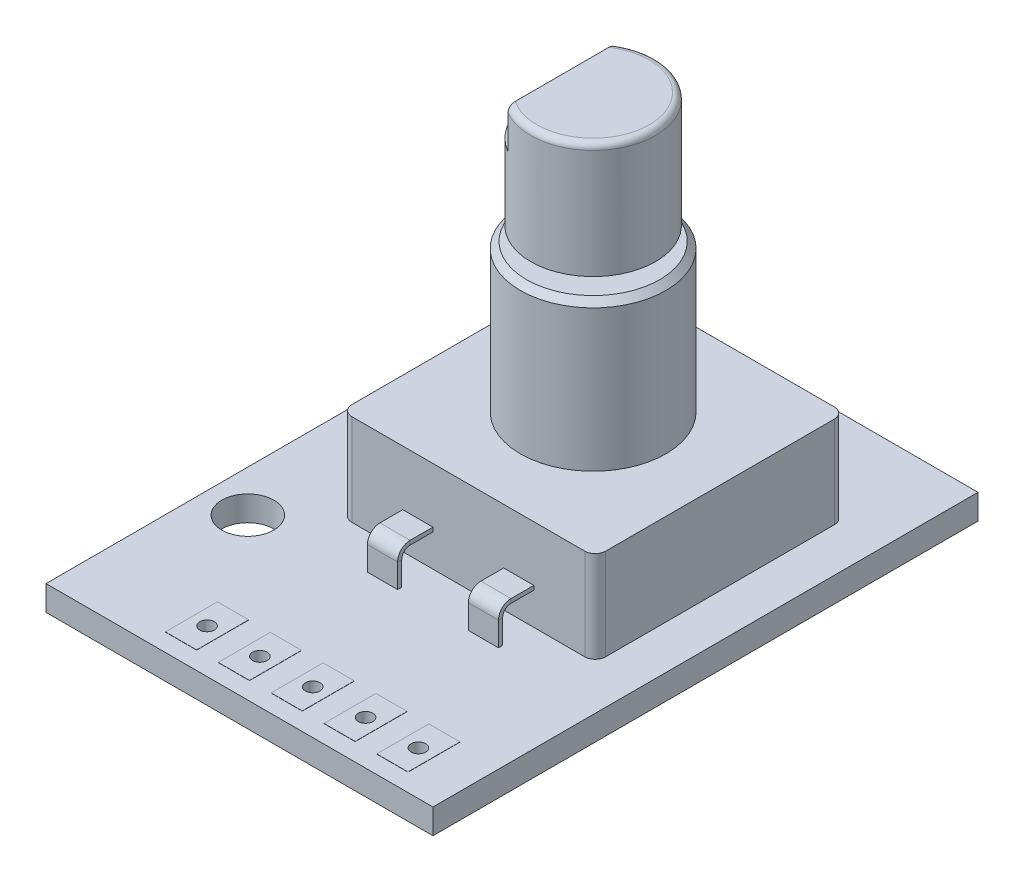
from build123d import *

# Parameters (mm, degrees)
SKETCH1_W             = 18.6
SKETCH1_H             = 26.2
SKETCH1_R             = 1.25
BOSS_EXTRUDE1_DEPTH   = 1.2
SKETCH3_W             = 12.2
SKETCH3_H             = 12
BOSS_EXTRUDE2_DEPTH   = 4.4
SKETCH10_W            = 1.45
SKETCH10_H            = 0.2
SKETCH13_W            = 1.45
SKETCH13_H            = 0.2
LPATTERN1_COUNT       = 2
LPATTERN1_PITCH       = 2.85
LPATTERN2_COUNT       = 2
LPATTERN2_PITCH       = 2.85
SKETCH14_R            = 3.5
BOSS_EXTRUDE4_DEPTH   = 7.1
CHAMFER1_SIZE         = 0.3
SKETCH15_R            = 1.9
BOSS_EXTRUDE5_DEPTH   = 0.65
SKETCH16_R            = 3
BOSS_EXTRUDE6_DEPTH   = 14.45
CHAMFER2_SIZE         = 0.6
CUT_EXTRUDE1_DEPTH    = 10.8
SKETCH18_R            = 0.35
CUT_EXTRUDE2_DEPTH    = 1.2
SKETCH19_W            = 1.5
SKETCH19_H            = 2.5
SKETCH19_R            = 0.35
BOSS_EXTRUDE7_DEPTH   = 0.01
FILLET1_R             = 0.5
CROQUIS1_R            = 3.5
CORTAR_EXTRUIR1_DEPTH = 8.9
REDONDEO1_R           = 0.3


with BuildPart() as part:
    # Sketch1 → Boss-Extrude1 (new body)
    with BuildSketch(Plane(origin=(0, 0, 0), x_dir=(1, 0, 0), z_dir=(0, 1, 0))):
        Rectangle(SKETCH1_W, SKETCH1_H)
        with Locations((-7.3, 8.3)):
            Circle(SKETCH1_R, mode=Mode.SUBTRACT)
        with Locations((-7.3, -5.4)):
            Circle(SKETCH1_R, mode=Mode.SUBTRACT)
    extrude(amount=BOSS_EXTRUDE1_DEPTH)

    # Sketch3 → Boss-Extrude2 (add)
    with BuildSketch(Plane(origin=(0, 1.2, 0), x_dir=(1, 0, 0), z_dir=(0, 1, 0))):
        with Locations((1.1, 2.8)):
            Rectangle(SKETCH3_W, SKETCH3_H)
    extrude(amount=BOSS_EXTRUDE2_DEPTH)

    # Sweep3: sweep along a curve in space
    with BuildLine() as sweep3_path:
        Line((-1.325, 2.85, 3.2), (-1.325, 2.85, 4.3))
        ThreePointArc((-1.325, 2.85, 4.3), (-1.325, 2.703553391, 4.653553391), (-1.325, 2.35, 4.8))
        Line((-1.325, 2.35, 4.8), (-1.325, 1.2, 4.8))
    # Sketch10 → Sweep3 (sweep)
    with BuildSketch(Plane.XY.offset(3.2)):
        with Locations((-1.325, 2.85)):
            Rectangle(SKETCH10_W, SKETCH10_H)
    sweep3 = sweep(path=sweep3_path.line)

    # Mirror2: Sweep3 across plane
    add(sweep3.mirror(Plane.ZY.offset(-1.1)))

    # Sweep4: sweep along a curve in space
    with BuildLine() as sweep4_path:
        Line((1.1, 2.8, -8.8), (1.1, 2.8, -9.75))
        ThreePointArc((1.1, 2.8, -9.75), (1.1, 2.653553391, -10.103553391), (1.1, 2.3, -10.25))
        Line((1.1, 2.3, -10.25), (1.1, 1.2, -10.25))
    # Sketch13 → Sweep4 (sweep)
    with BuildSketch(Plane(origin=(0, 0, -8.8), x_dir=(-1, 0, 0), z_dir=(0, 0, -1))):
        with Locations((-1.1, 2.8)):
            Rectangle(SKETCH13_W, SKETCH13_H)
    sweep4 = sweep(path=sweep4_path.line)

    # LPattern1: Sweep4 ×2
    with Locations(*[(-i * LPATTERN1_PITCH, 0, 0) for i in range(1, LPATTERN1_COUNT)]):
        add(sweep4)

    # LPattern2: Sweep4 ×2
    with Locations(*[(i * LPATTERN2_PITCH, 0, 0) for i in range(1, LPATTERN2_COUNT)]):
        add(sweep4)

    # Sketch14 → Boss-Extrude4 (add)
    with BuildSketch(Plane(origin=(0, 5.6, 0), x_dir=(1, 0, 0), z_dir=(0, 1, 0))):
        with Locations((1.1, 2.8)):
            Circle(SKETCH14_R)
    extrude(amount=BOSS_EXTRUDE4_DEPTH)

    # Chamfer1
    chamfer1_edges = [part.edges().sort_by_distance(p)[0] for p in [
        (-2.4, 12.7, -2.8),
    ]]
    chamfer(chamfer1_edges, length=CHAMFER1_SIZE)

    # Sketch15 → Boss-Extrude5 (add)
    with BuildSketch(Plane(origin=(0, 12.7, 0), x_dir=(1, 0, 0), z_dir=(0, 1, 0))):
        with Locations((1.1, 2.8)):
            Circle(SKETCH15_R)
    extrude(amount=BOSS_EXTRUDE5_DEPTH)

    # Sketch16 → Boss-Extrude6 (add)
    with BuildSketch(Plane(origin=(0, 13.35, 0), x_dir=(1, 0, 0), z_dir=(0, 1, 0))):
        with Locations((1.1, 2.8)):
            Circle(SKETCH16_R)
    extrude(amount=BOSS_EXTRUDE6_DEPTH)

    # Chamfer2
    chamfer2_edges = [part.edges().sort_by_distance(p)[0] for p in [
        (-1.9, 27.8, -2.8),
    ]]
    chamfer(chamfer2_edges, length=CHAMFER2_SIZE)

    # Sketch17 → Cut-Extrude1 (cut)
    with BuildSketch(Plane(origin=(0, 27.8, 0), x_dir=(1, 0, 0), z_dir=(0, 1, 0))):
        with BuildLine():
            Line((-0.396662955, 5.4), (-0.396662955, 0.2))
            ThreePointArc((-0.396662955, 0.2), (-1.9, 2.8), (-0.396662955, 5.4))
        make_face()
    extrude(amount=-CUT_EXTRUDE1_DEPTH, mode=Mode.SUBTRACT)

    # Sketch18 → Cut-Extrude2 (cut)
    with BuildSketch(Plane(origin=(0, 1.2, 0), x_dir=(1, 0, 0), z_dir=(0, 1, 0))):
        with Locations((6.5, -11)):
            Circle(SKETCH18_R)
        with Locations((3.96, -11)):
            Circle(SKETCH18_R)
        with Locations((1.42, -11)):
            Circle(SKETCH18_R)
        with Locations((-1.12, -11)):
            Circle(SKETCH18_R)
        with Locations((-3.66, -11)):
            Circle(SKETCH18_R)
    extrude(amount=-CUT_EXTRUDE2_DEPTH, mode=Mode.SUBTRACT)

    # Sketch19 → Boss-Extrude7 (add)
    with BuildSketch(Plane(origin=(0, 1.2, 0), x_dir=(1, 0, 0), z_dir=(0, 1, 0))):
        with Locations((3.96, -11)):
            Rectangle(SKETCH19_W, SKETCH19_H)
        with Locations((3.96, -11)):
            Circle(SKETCH19_R, mode=Mode.SUBTRACT)
        with Locations((6.5, -11)):
            Rectangle(SKETCH19_W, SKETCH19_H)
        with Locations((6.5, -11)):
            Circle(SKETCH19_R, mode=Mode.SUBTRACT)
        with Locations((1.42, -11)):
            Rectangle(SKETCH19_W, SKETCH19_H)
        with Locations((1.42, -11)):
            Circle(SKETCH19_R, mode=Mode.SUBTRACT)
        with Locations((-1.12, -11)):
            Rectangle(SKETCH19_W, SKETCH19_H)
        with Locations((-1.12, -11)):
            Circle(SKETCH19_R, mode=Mode.SUBTRACT)
        with Locations((-3.66, -11)):
            Rectangle(SKETCH19_W, SKETCH19_H)
        with Locations((-3.66, -11)):
            Circle(SKETCH19_R, mode=Mode.SUBTRACT)
    boss_extrude7 = extrude(amount=BOSS_EXTRUDE7_DEPTH)

    # Mirror3: Boss-Extrude7 across plane
    add(boss_extrude7.mirror(Plane.ZX.offset(0.6)))

    # Fillet1
    fillet1_edges = [part.edges().sort_by_distance(p)[0] for p in [
        (7.2, 3.4, 3.2),
        (7.2, 3.4, -8.8),
        (-5, 3.4, -8.8),
        (-5, 3.4, 3.2),
    ]]
    fillet(fillet1_edges, radius=FILLET1_R)

    # Croquis1 → Cortar-Extruir1 (cut)
    with BuildSketch(Plane(origin=(0, 27.8, 0), x_dir=(1, 0, 0), z_dir=(0, 1, 0))):
        with Locations((1.1, 2.8)):
            Circle(CROQUIS1_R)
    extrude(amount=-CORTAR_EXTRUIR1_DEPTH, mode=Mode.SUBTRACT)

    # Redondeo1
    redondeo1_edges = [part.edges().sort_by_distance(p)[0] for p in [
        (2.601667596, 18.9, -5.397112711),
    ]]
    fillet(redondeo1_edges, radius=REDONDEO1_R)


solid = part.part
